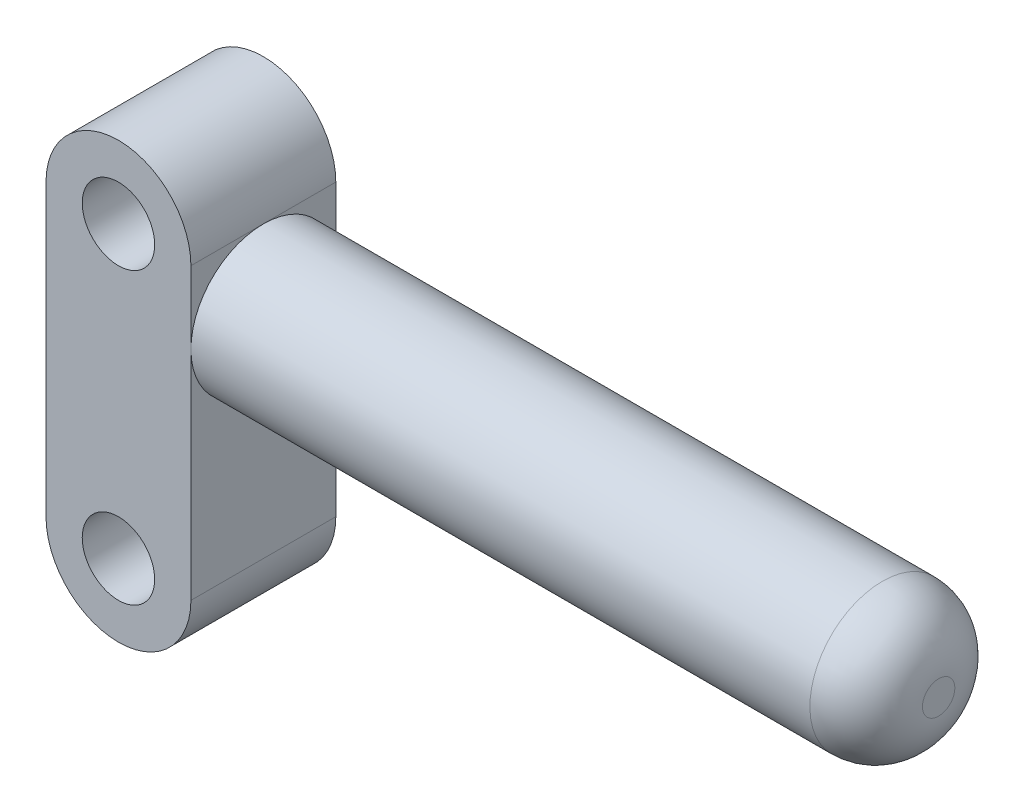
from build123d import *

# Parameters (mm, degrees)
ESQUISSE1_R        = 2.5
BOSS_EXTRU_1_DEPTH = 5
ESQUISSE2_R        = 5
BOSS_EXTRU_2_DEPTH = 46.6
CONG_1_R           = 3.883333333


with BuildPart() as part:
    # Esquisse1 → Boss.-Extru.1 (new, symmetric)
    with BuildSketch(Plane.XY):
        with BuildLine():
            Line((5, 10), (5, -10))
            ThreePointArc((5, -10), (0, -15), (-5, -10))
            Line((-5, -10), (-5, 10))
            ThreePointArc((-5, 10), (0, 15), (5, 10))
        make_face()
        with Locations((0, 10)):
            Circle(ESQUISSE1_R, mode=Mode.SUBTRACT)
        with Locations((0, -10)):
            Circle(ESQUISSE1_R, mode=Mode.SUBTRACT)
    extrude(amount=BOSS_EXTRU_1_DEPTH, both=True)

    # Esquisse2 → Boss.-Extru.2 (add)
    with BuildSketch(Plane(origin=(5, 0, 0), x_dir=(0, 0, -1), z_dir=(1, 0, 0))):
        with Locations((0, 5)):
            Circle(ESQUISSE2_R)
    extrude(amount=BOSS_EXTRU_2_DEPTH)

    # Congé1
    cong_1_edges = [part.edges().sort_by_distance(p)[0] for p in [
        (51.6, 5, 5),
    ]]
    fillet(cong_1_edges, radius=CONG_1_R)


solid = part.part
